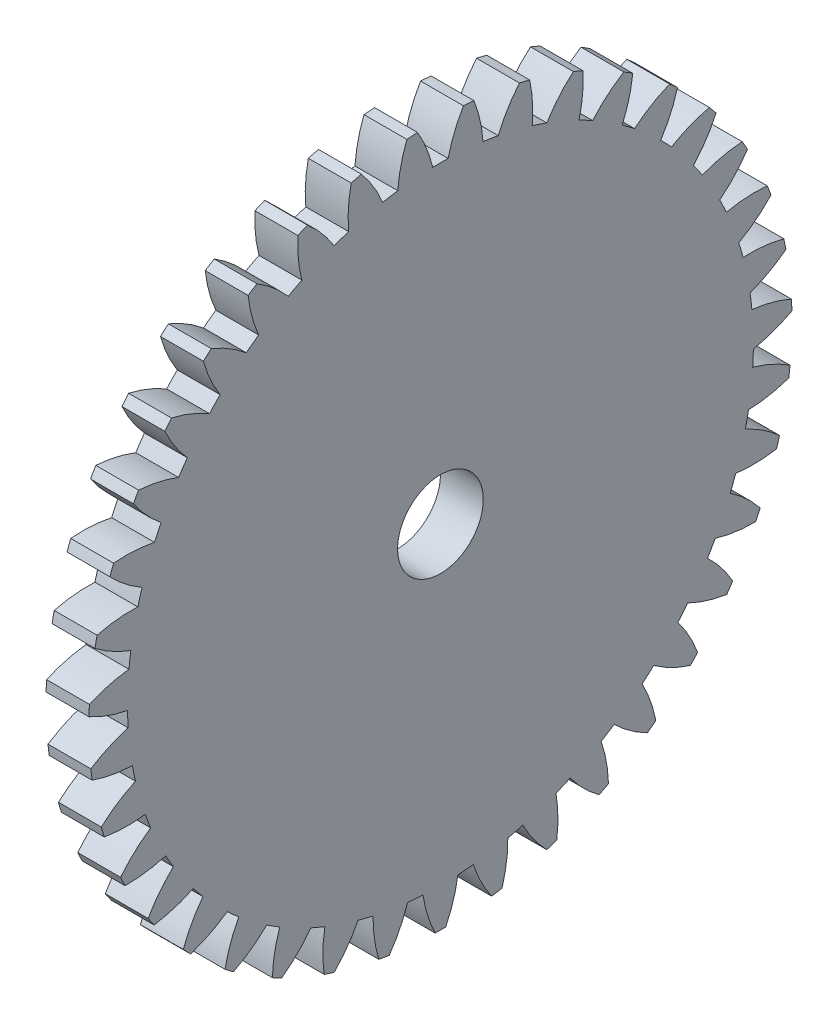
from build123d import *

# Parameters (mm, degrees)
BASPROSKE_W     = 1
BASPROSKE_H     = 8.2
TOOTHCUT_DEPTH  = 12.639587622
TEETHCUTS_COUNT = 39
TEETHCUTS_ANGLE = 350.769230769
BORSKE_R        = 1
BORE_DEPTH      = 50.0000508


with BuildPart() as part:
    # BasProSke → Base-Revolve (revolve)
    with BuildSketch(Plane(origin=(0, 0, 0), x_dir=(1, 0, 0), z_dir=(0, 1, 0)), mode=Mode.PRIVATE) as base_revolve_sk:
        with Locations((0.5, 4.1)):
            Rectangle(BASPROSKE_W, BASPROSKE_H)
    revolve(base_revolve_sk.sketch.rotate(Axis((-10, 0, 0), (1, 0, 0)), 180), axis=Axis((-10, 0, 0), (1, 0, 0)))

    # TooCutSke → ToothCut (cut, through all)
    with BuildSketch(Plane(origin=(0, 0, 0), x_dir=(0, 0, -1), z_dir=(1, 0, 0))):
        with BuildLine():
            ThreePointArc((0.179558021, 7.29679107), (0, 7.299), (-0.179558021, 7.29679107))
            ThreePointArc((-0.179558021, 7.29679107), (-0.329557504, 7.766585874), (-0.551708626, 8.206876553))
            ThreePointArc((-0.551708626, 8.206876553), (0, 8.2254), (0.551708626, 8.206876553))
            ThreePointArc((0.551708626, 8.206876553), (0.329557504, 7.766585874), (0.179558021, 7.29679107))
        make_face()
    toothcut = extrude(amount=TOOTHCUT_DEPTH, mode=Mode.SUBTRACT)

    # TeethCuts: ToothCut ×39 about axis
    teethcuts_axis = Axis((-10, 0, 0), (1, 0, 0))
    for i in range(1, TEETHCUTS_COUNT):
        add(toothcut.rotate(teethcuts_axis, i * TEETHCUTS_ANGLE / (TEETHCUTS_COUNT - 1)), mode=Mode.SUBTRACT)

    # BorSke → Bore (cut, symmetric)
    with BuildSketch(Plane(origin=(0, 0, 0), x_dir=(0, 0, -1), z_dir=(1, 0, 0))):
        with Locations(Location((0, 0, 0), (0, 0, 180))):
            Circle(BORSKE_R)
    extrude(amount=BORE_DEPTH, both=True, mode=Mode.SUBTRACT)


solid = part.part
